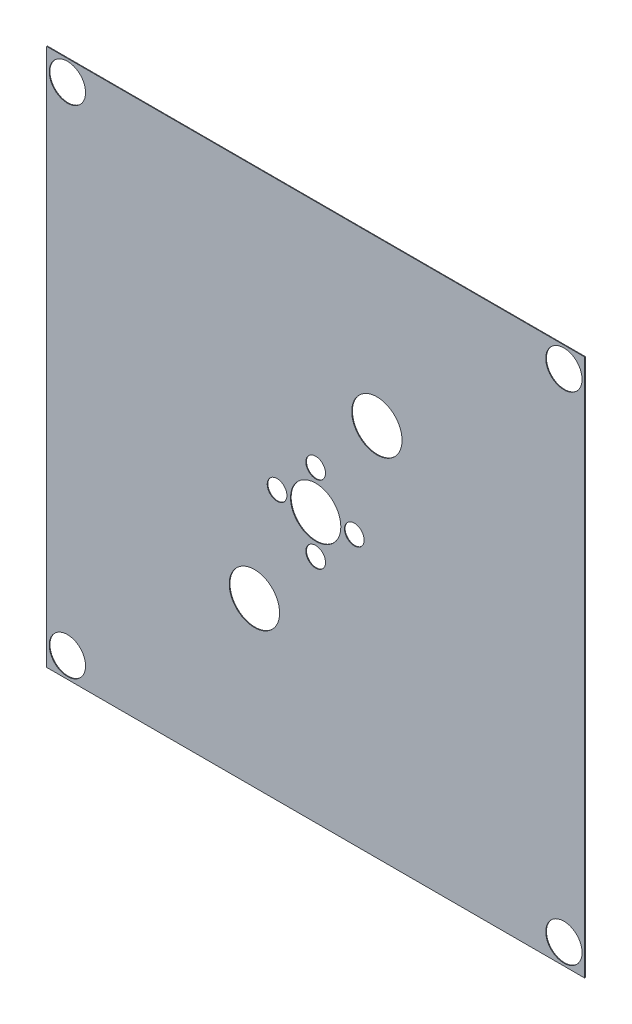
from build123d import *

# Parameters (mm, degrees)
SKETCH1_W           = 1950
SKETCH1_H           = 1950
BOSS_EXTRUDE1_DEPTH = 2.4
SKETCH2_R           = 91.2
SKETCH2_R_2         = 35.65
SKETCH2_R_3         = 65.8
CUT_EXTRUDE1_DEPTH  = 3.4


with BuildPart() as part:
    # Sketch1 → Boss-Extrude1 (new body)
    with BuildSketch(Plane.XY):
        Rectangle(SKETCH1_W, SKETCH1_H)
    extrude(amount=BOSS_EXTRUDE1_DEPTH)

    # Sketch2 → Cut-Extrude1 (cut, through all)
    with BuildSketch(Plane.XY.offset(2.4)):
        Circle(SKETCH2_R)
        with Locations((0, 140)):
            Circle(SKETCH2_R_2)
        with Locations((222, 382)):
            Circle(SKETCH2_R)
        with Locations((-222, -382)):
            Circle(SKETCH2_R)
        with Locations((-900, 900)):
            Circle(SKETCH2_R_3)
        with Locations((-900, -900)):
            Circle(SKETCH2_R_3)
        with Locations((0, -140)):
            Circle(SKETCH2_R_2)
        with Locations((900, 900)):
            Circle(SKETCH2_R_3)
        with Locations((140, 0)):
            Circle(SKETCH2_R_2)
        with Locations((-140, 0)):
            Circle(SKETCH2_R_2)
        with Locations((900, -900)):
            Circle(SKETCH2_R_3)
    extrude(amount=-CUT_EXTRUDE1_DEPTH, mode=Mode.SUBTRACT)


solid = part.part
